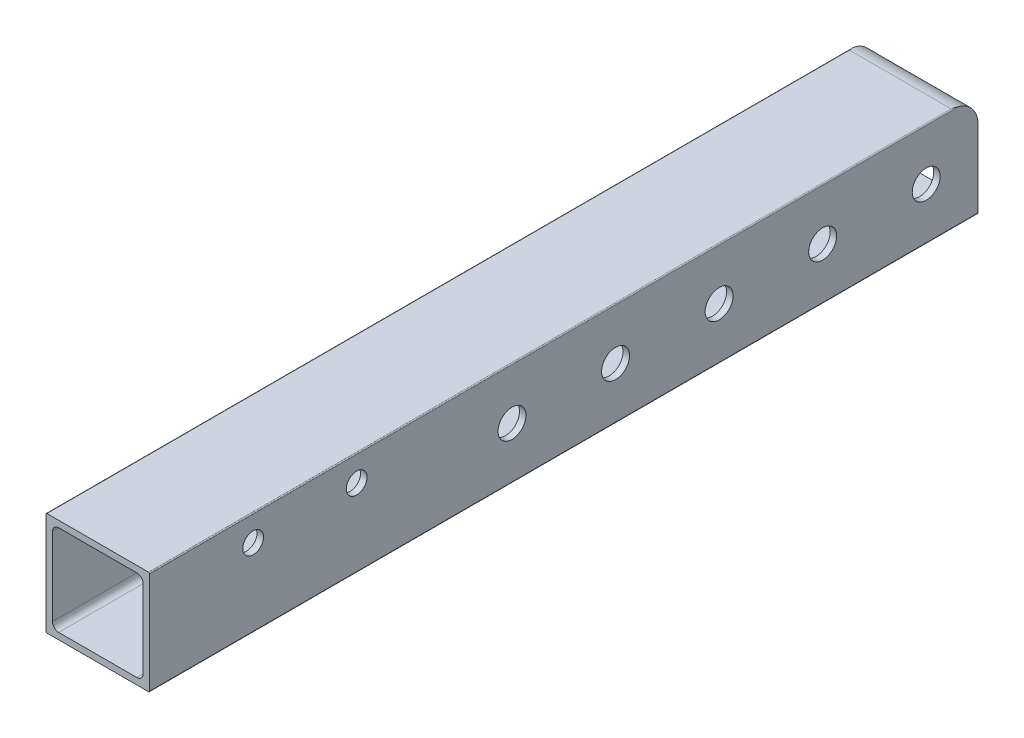
from build123d import *

# Parameters (mm, degrees)
BOSS_EXTRUDE1_DEPTH = 203.2
SKETCH2_R           = 3.429
SKETCH2_R_2         = 2.54
CUT_EXTRUDE1_DEPTH  = 26.4


with BuildPart() as part:
    # Sketch1 → Boss-Extrude1 (new body)
    with BuildSketch(Plane.XY):
        with BuildLine():
            Line((-12.446, -12.7), (12.446, -12.7))
            ThreePointArc((12.446, -12.7), (12.625605122, -12.625605122), (12.7, -12.446))
            Line((12.7, -12.446), (12.7, 12.446))
            ThreePointArc((12.7, 12.446), (12.625605122, 12.625605122), (12.446, 12.7))
            Line((12.446, 12.7), (-12.446, 12.7))
            ThreePointArc((-12.446, 12.7), (-12.625605122, 12.625605122), (-12.7, 12.446))
            Line((-12.7, 12.446), (-12.7, -12.446))
            ThreePointArc((-12.7, -12.446), (-12.625605122, -12.625605122), (-12.446, -12.7))
        make_face()
        with BuildLine():
            Line((-9.5885, 11.1125), (9.5885, 11.1125))
            ThreePointArc((9.5885, 11.1125), (10.666130735, 10.666130735), (11.1125, 9.5885))
            Line((11.1125, 9.5885), (11.1125, -9.5885))
            ThreePointArc((11.1125, -9.5885), (10.666130735, -10.666130735), (9.5885, -11.1125))
            Line((9.5885, -11.1125), (-9.5885, -11.1125))
            ThreePointArc((-9.5885, -11.1125), (-10.666130735, -10.666130735), (-11.1125, -9.5885))
            Line((-11.1125, -9.5885), (-11.1125, 9.5885))
            ThreePointArc((-11.1125, 9.5885), (-10.666130735, 10.666130735), (-9.5885, 11.1125))
        make_face(mode=Mode.SUBTRACT)
    extrude(amount=BOSS_EXTRUDE1_DEPTH)

    # Sketch2 → Cut-Extrude1 (cut, through all)
    with BuildSketch(Plane.ZY.offset(12.7)):
        with Locations((12.7, 0)):
            Circle(SKETCH2_R)
        with Locations((38.1, 0)):
            Circle(SKETCH2_R)
        with Locations((63.5, 0)):
            Circle(SKETCH2_R)
        with Locations((88.9, 0)):
            Circle(SKETCH2_R)
        with Locations((114.3, 0)):
            Circle(SKETCH2_R)
        with Locations((177.8, 6.35)):
            Circle(SKETCH2_R_2)
        with Locations((152.4, 6.35)):
            Circle(SKETCH2_R_2)
        with BuildLine():
            Line((6.35, 12.7), (0, 12.7))
            Line((0, 12.7), (0, 6.35))
            ThreePointArc((0, 6.35), (1.859871939, 10.840128061), (6.35, 12.7))
        make_face()
    extrude(amount=-CUT_EXTRUDE1_DEPTH, mode=Mode.SUBTRACT)


solid = part.part
